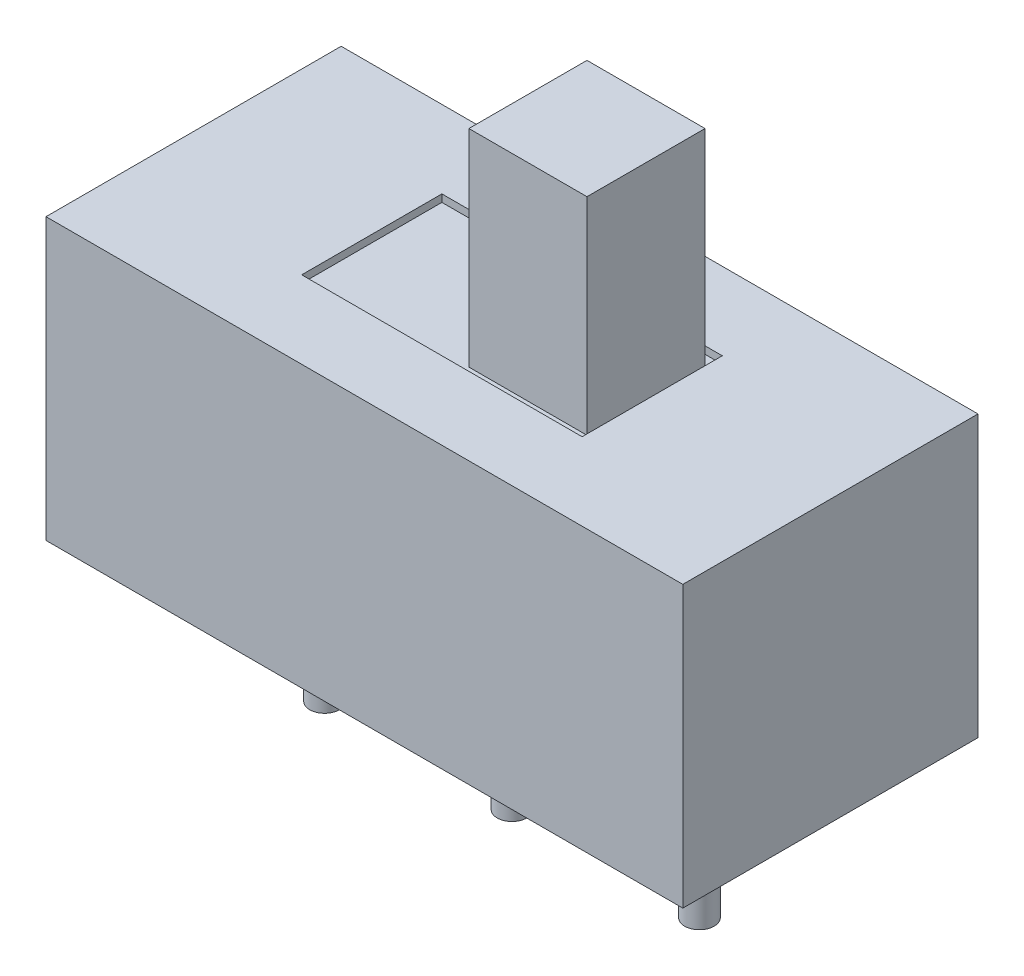
from build123d import *

# Parameters (mm, degrees)
SKETCH_1_W          = 8.63
SKETCH_1_H          = 4
EXTRUDE_1_DEPTH     = 3.8
SKETCH_2_W          = 3.8
SKETCH_2_H          = 1.9
CUT_EXTRUDE_1_DEPTH = 0.1
SKETCH_3_W          = 1.6
SKETCH_3_H          = 1.6
EXTRUDE_2_DEPTH     = 2.8
SKETCH_4_R          = 0.2
EXTRUDE_3_DEPTH     = 2


with BuildPart() as part:
    # Эскиз1 → Бобышка-Вытянуть1 (new body)
    with BuildSketch(Plane(origin=(0, 0, 0), x_dir=(1, 0, 0), z_dir=(0, 1, 0))):
        Rectangle(SKETCH_1_W, SKETCH_1_H)
    extrude(amount=EXTRUDE_1_DEPTH)

    # Эскиз2 → Вырез-Вытянуть1 (cut)
    with BuildSketch(Plane(origin=(0, 3.8, 0), x_dir=(1, 0, 0), z_dir=(0, 1, 0))):
        Rectangle(SKETCH_2_W, SKETCH_2_H)
    extrude(amount=-CUT_EXTRUDE_1_DEPTH, mode=Mode.SUBTRACT)

    # Эскиз3 → Бобышка-Вытянуть2 (add)
    with BuildSketch(Plane(origin=(0, 3.7, 0), x_dir=(1, 0, 0), z_dir=(0, 1, 0))):
        with Locations((1.01593525, 0)):
            Rectangle(SKETCH_3_W, SKETCH_3_H)
    extrude(amount=EXTRUDE_2_DEPTH)

    # Эскиз4 → Бобышка-Вытянуть3 (add)
    with BuildSketch(Plane.XZ):
        with Locations((-2.54, 0)):
            Circle(SKETCH_4_R)
        Circle(SKETCH_4_R)
        with Locations((2.54, 0)):
            Circle(SKETCH_4_R)
    extrude(amount=EXTRUDE_3_DEPTH)


solid = part.part
